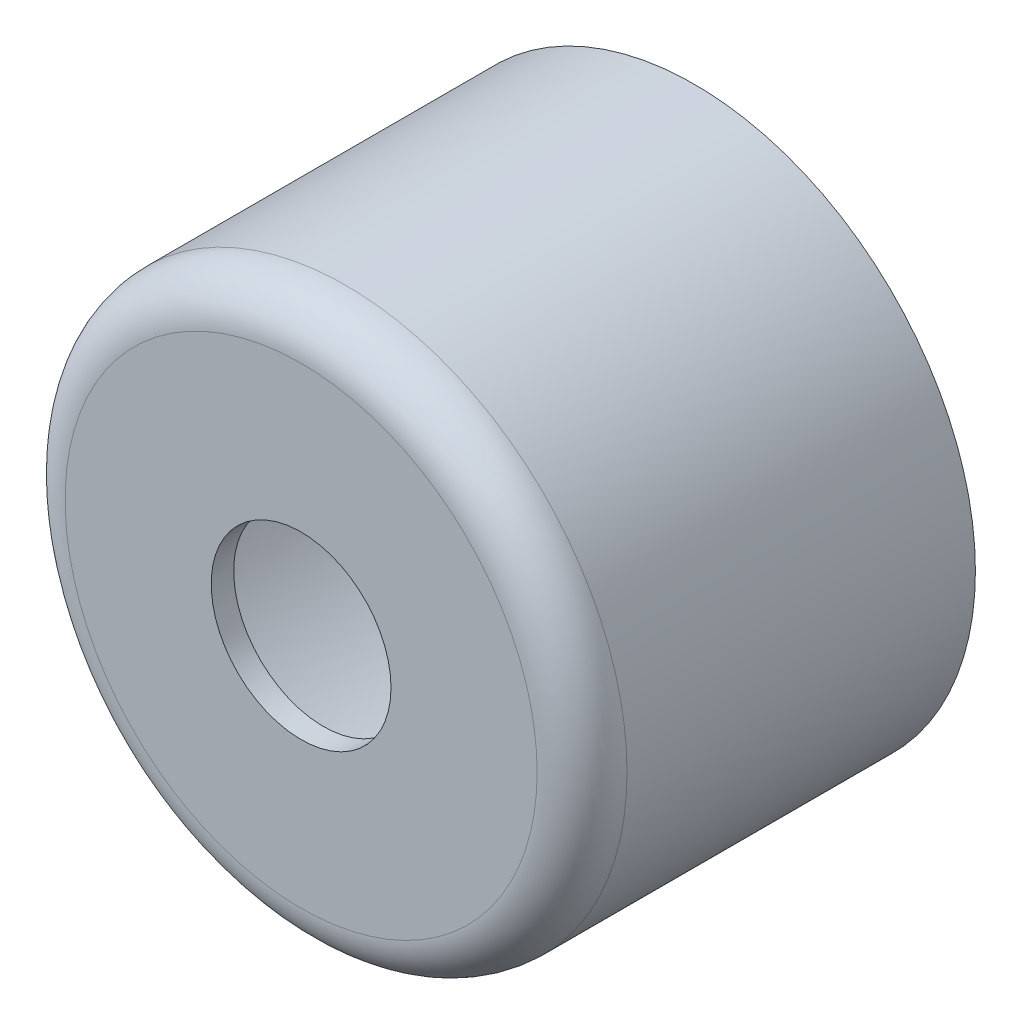
from build123d import *

# Parameters (mm, degrees)
SKETCH8_R      = 12.5
EXTRUDE6_DEPTH = 17.5
FILLET2_R      = 2
SHELL1_T       = -1
SKETCH9_R      = 4
EXTRUDE7_DEPTH = 25.874685978


with BuildPart() as part:
    # Sketch8 → Extrude6 (new body)
    with BuildSketch(Plane.XY):
        Circle(SKETCH8_R)
    extrude(amount=EXTRUDE6_DEPTH)

    # Fillet2
    fillet2_edges = [part.edges().sort_by_distance(p)[0] for p in [
        (-12.5, 0, 17.5),
    ]]
    fillet(fillet2_edges, radius=FILLET2_R)

    # Shell1
    shell1_openings = [part.faces().sort_by_distance(p)[0] for p in [
        (0, 0, 0),
    ]]
    offset(amount=SHELL1_T, openings=shell1_openings, kind=Kind.INTERSECTION)

    # Sketch9 → Extrude7 (cut, through all)
    with BuildSketch(Plane.XY.offset(17.5)):
        Circle(SKETCH9_R)
    extrude(amount=-EXTRUDE7_DEPTH, mode=Mode.SUBTRACT)


solid = part.part
